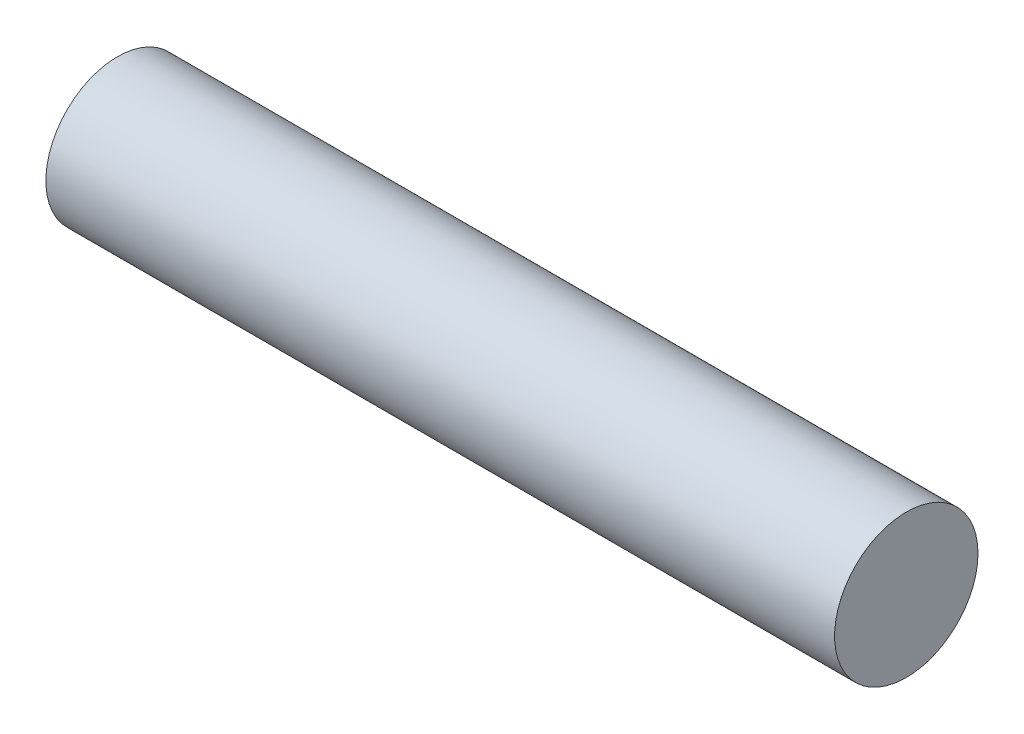
from build123d import *

# Parameters (mm, degrees)
SCHIZZO1_R                   = 2
ESTRUSIONE_ESTRUSIONE1_DEPTH = 22


with BuildPart() as part:
    # Schizzo1 → Estrusione-Estrusione1 (new body)
    with BuildSketch(Plane(origin=(0, 0, 0), x_dir=(0, 0, -1), z_dir=(1, 0, 0))):
        Circle(SCHIZZO1_R)
    extrude(amount=ESTRUSIONE_ESTRUSIONE1_DEPTH)


solid = part.part
